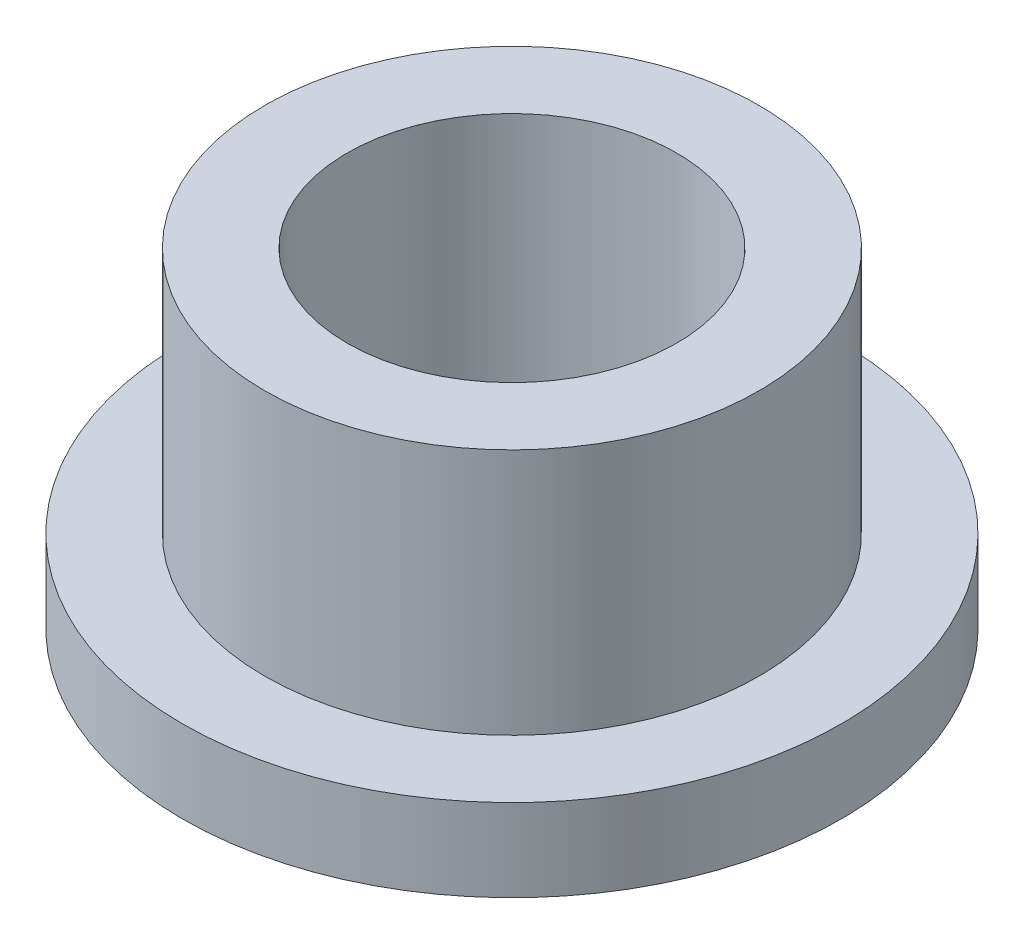
from build123d import *

# Parameters (mm, degrees)
SKETCH1_R           = 6.35
SKETCH1_R_2         = 3.175
BOSS_EXTRUDE1_DEPTH = 1.5875
SKETCH2_R           = 4.7625
SKETCH2_R_2         = 3.175
BOSS_EXTRUDE2_DEPTH = 6.35


with BuildPart() as part:
    # Sketch1 → Boss-Extrude1 (new body)
    with BuildSketch(Plane(origin=(0, 0, 0), x_dir=(1, 0, 0), z_dir=(0, 1, 0))):
        Circle(SKETCH1_R)
        Circle(SKETCH1_R_2, mode=Mode.SUBTRACT)
    extrude(amount=BOSS_EXTRUDE1_DEPTH)

    # Sketch2 → Boss-Extrude2 (add)
    with BuildSketch(Plane(origin=(0, 0, 0), x_dir=(1, 0, 0), z_dir=(0, 1, 0))):
        Circle(SKETCH2_R)
        Circle(SKETCH2_R_2, mode=Mode.SUBTRACT)
    extrude(amount=BOSS_EXTRUDE2_DEPTH)


solid = part.part
